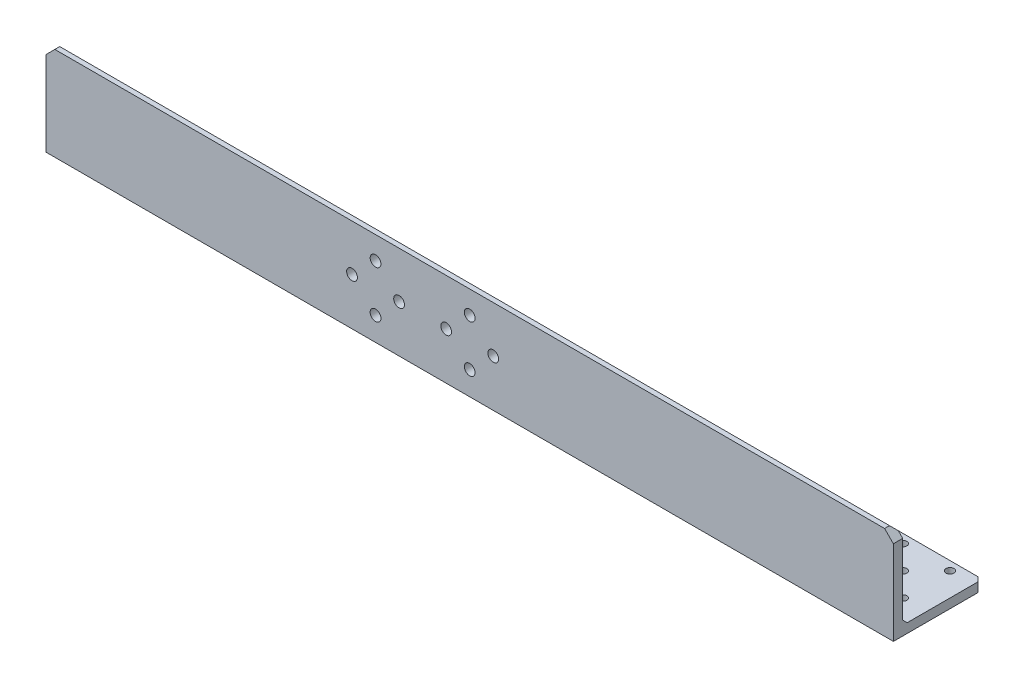
from build123d import *

# Parameters (mm, degrees)
BOSS_EXTRUDE1_DEPTH   = 144
CHAMFER1_SIZE         = 1.5
CHAMFER2_SIZE         = 3
F_6_32_TAPPED_HOLE1_D = 2.7051
F_6_CLEARANCE_HOLE1_D = 3.6576


with BuildPart() as part:
    # Sketch1 → Boss-Extrude1 (new, symmetric)
    with BuildSketch(Plane(origin=(0, 0, 0), x_dir=(0, 0, -1), z_dir=(1, 0, 0))):
        Polygon((0, 0), (31.75, 0), (31.75, 3.175), (3.175, 3.175), (3.175, 31.75), (0, 31.75), align=None)
    extrude(amount=BOSS_EXTRUDE1_DEPTH, both=True)

    # Chamfer1
    chamfer1_edges = [part.edges().sort_by_distance(p)[0] for p in [
        (0, 3.175, -31.75),
        (0, 3.175, -3.175),
        (0, 31.75, -3.175),
    ]]
    chamfer(chamfer1_edges, length=CHAMFER1_SIZE)

    # Chamfer2
    chamfer2_edges = [part.edges().sort_by_distance(p)[0] for p in [
        (-144, 31.75, -0.8375),
        (-144, 0.8375, -31.75),
        (144, 0.8375, -31.75),
        (144, 31.75, -0.8375),
    ]]
    chamfer(chamfer2_edges, length=CHAMFER2_SIZE)

    # 6-32 Tapped Hole1 (through all)
    with Locations(Plane(origin=(0, 3.175, 0), x_dir=(1, 0, 0), z_dir=(0, 1, 0))):
        with Locations((-136, 27.221), (-120, 27.221), (-128, 19.221), (-136, 11.221), (-120, 11.221), (120, 27.221), (136, 27.221), (128, 19.221), (120, 11.221), (136, 11.221)):
            Hole(F_6_32_TAPPED_HOLE1_D / 2)

    # 6 Clearance Hole1 (through all)
    with Locations(Plane(origin=(0, 0, -3.175), x_dir=(-1, 0, 0), z_dir=(0, 0, -1))):
        with Locations((0, 24), (-8, 16), (8, 16), (0, 8), (24, 16), (32, 24), (40, 16), (32, 8)):
            Hole(F_6_CLEARANCE_HOLE1_D / 2)


solid = part.part
